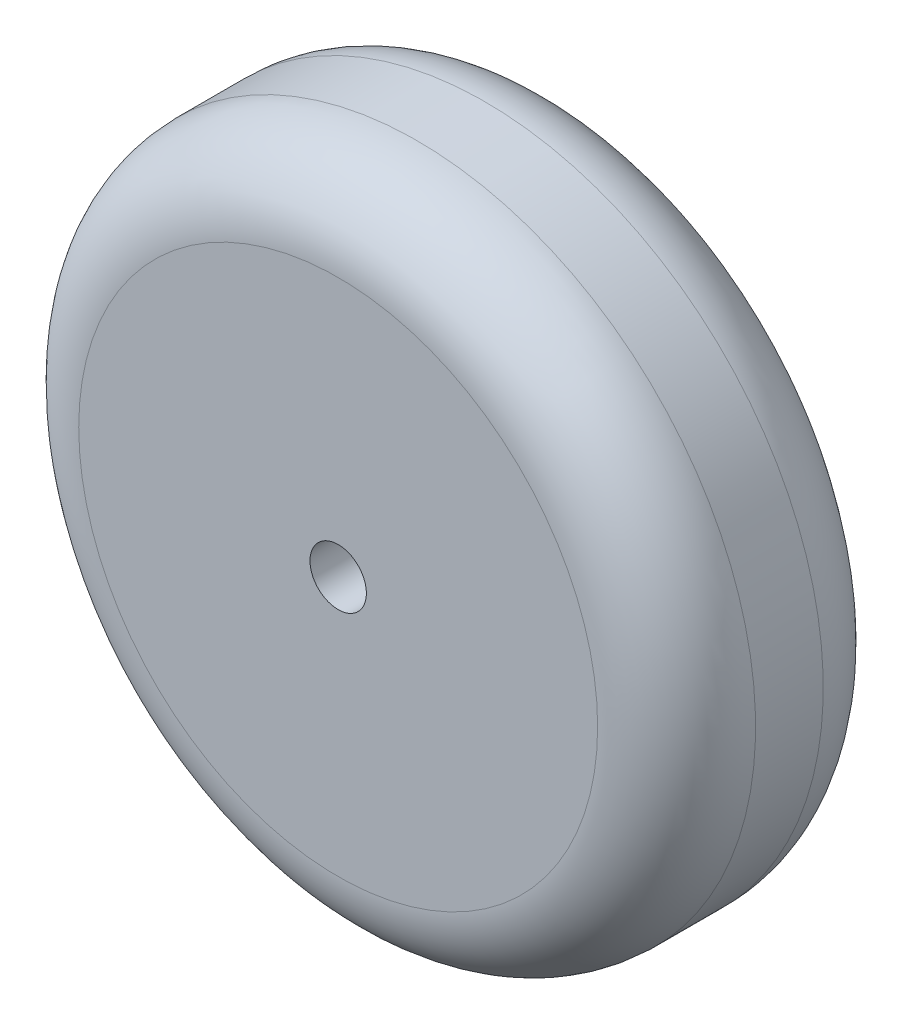
from build123d import *

# Parameters (mm, degrees)
SKETCH2_R               = 6.35
CUT_EXTRUDE1_DEPTH      = 108.458
CUT_EXTRUDE1_DEPTH_BACK = 134.62


with BuildPart() as part:
    # Sketch1 → Revolve2 (revolve)
    with BuildSketch(Plane(origin=(0, 0, 0), x_dir=(0, 0, -1), z_dir=(1, 0, 0))):
        with BuildLine():
            Line((-25.4, 0), (-25.4, 58.42))
            ThreePointArc((-25.4, 58.42), (-20.192358569, 70.992358569), (-7.62, 76.2))
            Line((-7.62, 76.2), (7.62, 76.2))
            ThreePointArc((7.62, 76.2), (20.192358569, 70.992358569), (25.4, 58.42))
            Line((25.4, 58.42), (25.4, 0))
            Line((25.4, 0), (-25.4, 0))
        make_face()
    revolve(axis=Axis((0, 0, -37.220072608), (0, 0, 1)))

    # Sketch2 → Cut-Extrude1 (cut, two sides)
    with BuildSketch(Plane.XY) as cut_extrude1_sk:
        Circle(SKETCH2_R)
    extrude(amount=CUT_EXTRUDE1_DEPTH, mode=Mode.SUBTRACT)
    extrude(cut_extrude1_sk.sketch, amount=-CUT_EXTRUDE1_DEPTH_BACK, mode=Mode.SUBTRACT)


solid = part.part
